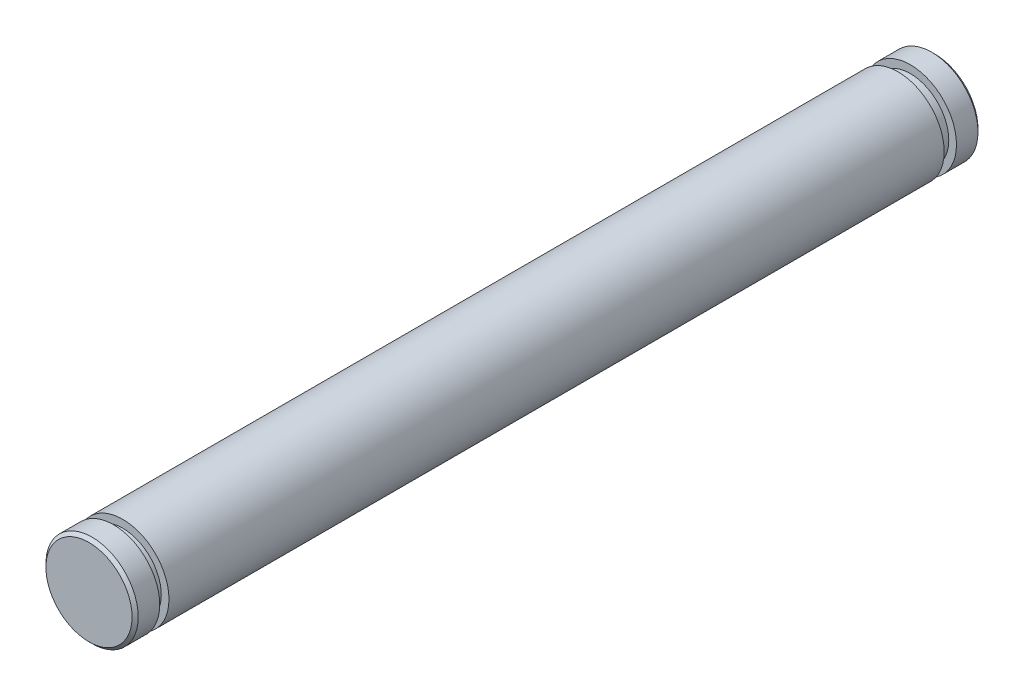
from build123d import *

# Parameters (mm, degrees)
SKETCH_1_R          = 1.5
EXTRUDE_1_DEPTH     = 27.5
SKETCH_2_R          = 1.5
SKETCH_2_R_2        = 1.25
CUT_EXTRUDE_1_DEPTH = 0.4
SKETCH_3_R          = 1.5
SKETCH_3_R_2        = 1.25
CUT_EXTRUDE_2_DEPTH = 0.3
CHAMFER_1_SIZE      = 0.1


with BuildPart() as part:
    # 草图1 → 凸台-拉伸1 (new body)
    with BuildSketch(Plane.XY):
        Circle(SKETCH_1_R)
    extrude(amount=EXTRUDE_1_DEPTH)

    # 草图2 → 切除-拉伸1 (cut)
    with BuildSketch(Plane.XY.offset(0.8)):
        Circle(SKETCH_2_R)
        Circle(SKETCH_2_R_2, mode=Mode.SUBTRACT)
    extrude(amount=CUT_EXTRUDE_1_DEPTH, mode=Mode.SUBTRACT)

    # 草图3 → 切除-拉伸2 (cut)
    with BuildSketch(Plane.XY.offset(26.7)):
        Circle(SKETCH_3_R)
        Circle(SKETCH_3_R_2, mode=Mode.SUBTRACT)
    extrude(amount=-CUT_EXTRUDE_2_DEPTH, mode=Mode.SUBTRACT)

    # 倒角1
    chamfer_1_edges = [part.edges().sort_by_distance(p)[0] for p in [
        (-1.5, 0, 0),
        (-1.5, 0, 27.5),
    ]]
    chamfer(chamfer_1_edges, length=CHAMFER_1_SIZE)


solid = part.part
